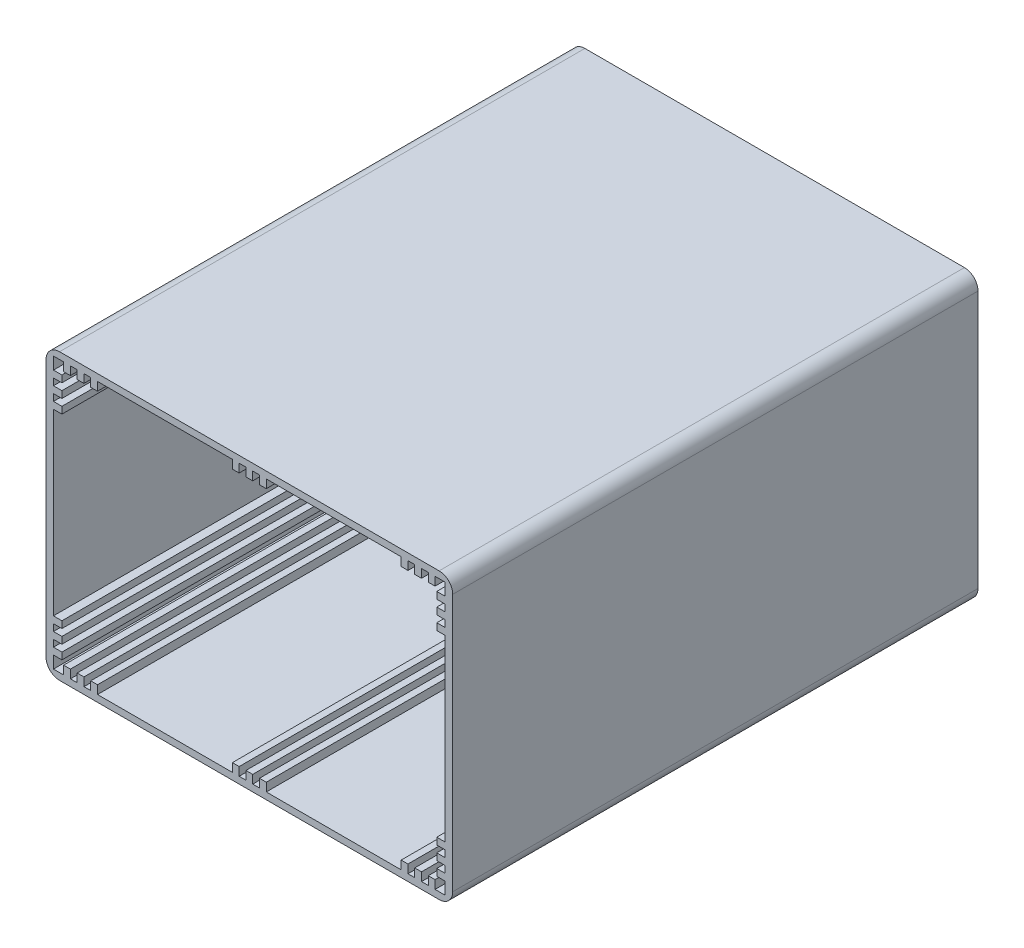
from build123d import *

# Parameters (mm, degrees)
SKETCH1_W           = 120
SKETCH1_H           = 84
SKETCH1_W_2         = 115.6
SKETCH1_H_2         = 80
BOSS_EXTRUDE1_DEPTH = 155
FILLET1_R           = 4
SKETCH3_W           = 2
SKETCH3_H           = 2.5
SKETCH3_W_2         = 2.5
SKETCH3_H_2         = 2
FINALBOX_DEPTH      = 155


with BuildPart() as part:
    # Sketch1 → Boss-Extrude1 (new body)
    with BuildSketch(Plane.XY):
        Rectangle(SKETCH1_W, SKETCH1_H)
        Rectangle(SKETCH1_W_2, SKETCH1_H_2, mode=Mode.SUBTRACT)
    extrude(amount=BOSS_EXTRUDE1_DEPTH)

    # Fillet1
    fillet1_edges = [part.edges().sort_by_distance(p)[0] for p in [
        (60, -42, 77.5),
        (-60, -42, 77.5),
        (-60, 42, 77.5),
        (60, 42, 77.5),
    ]]
    fillet(fillet1_edges, radius=FILLET1_R)

    # Sketch3 → FinalBox (add, through all)
    with BuildSketch(Plane.XY.offset(155)):
        with Locations((-53.8, 38.75)):
            Rectangle(SKETCH3_W, SKETCH3_H)
        with Locations((-49.8, 38.75)):
            Rectangle(SKETCH3_W, SKETCH3_H)
        with Locations((-45.8, 38.75)):
            Rectangle(SKETCH3_W, SKETCH3_H)
        with Locations((-56.55, 35.4)):
            Rectangle(SKETCH3_W_2, SKETCH3_H_2)
        with Locations((-56.55, 31.4)):
            Rectangle(SKETCH3_W_2, SKETCH3_H_2)
        with Locations((-56.55, 27.4)):
            Rectangle(SKETCH3_W_2, SKETCH3_H_2)
        with Locations((56.55, 27.4)):
            Rectangle(SKETCH3_W_2, SKETCH3_H_2)
        with Locations((56.55, 31.4)):
            Rectangle(SKETCH3_W_2, SKETCH3_H_2)
        with Locations((56.55, 35.4)):
            Rectangle(SKETCH3_W_2, SKETCH3_H_2)
        with Locations((53.8, 38.75)):
            Rectangle(SKETCH3_W, SKETCH3_H)
        with Locations((49.8, 38.75)):
            Rectangle(SKETCH3_W, SKETCH3_H)
        with Locations((45.8, 38.75)):
            Rectangle(SKETCH3_W, SKETCH3_H)
        with Locations((45.8, -38.75)):
            Rectangle(SKETCH3_W, SKETCH3_H)
        with Locations((49.8, -38.75)):
            Rectangle(SKETCH3_W, SKETCH3_H)
        with Locations((53.8, -38.75)):
            Rectangle(SKETCH3_W, SKETCH3_H)
        with Locations((56.55, -35.4)):
            Rectangle(SKETCH3_W_2, SKETCH3_H_2)
        with Locations((56.55, -31.4)):
            Rectangle(SKETCH3_W_2, SKETCH3_H_2)
        with Locations((56.55, -27.4)):
            Rectangle(SKETCH3_W_2, SKETCH3_H_2)
        with Locations((-45.8, -38.75)):
            Rectangle(SKETCH3_W, SKETCH3_H)
        with Locations((-49.8, -38.75)):
            Rectangle(SKETCH3_W, SKETCH3_H)
        with Locations((-53.8, -38.75)):
            Rectangle(SKETCH3_W, SKETCH3_H)
        with Locations((-56.55, -35.4)):
            Rectangle(SKETCH3_W_2, SKETCH3_H_2)
        with Locations((-56.55, -31.4)):
            Rectangle(SKETCH3_W_2, SKETCH3_H_2)
        with Locations((-56.55, -27.4)):
            Rectangle(SKETCH3_W_2, SKETCH3_H_2)
        with Locations((-4, -38.75)):
            Rectangle(SKETCH3_W, SKETCH3_H)
        with Locations((-4, 38.75)):
            Rectangle(SKETCH3_W, SKETCH3_H)
        with Locations((0, 38.75)):
            Rectangle(SKETCH3_W, SKETCH3_H)
        with Locations((4, 38.75)):
            Rectangle(SKETCH3_W, SKETCH3_H)
        with Locations((0, -38.75)):
            Rectangle(SKETCH3_W, SKETCH3_H)
        with Locations((4, -38.75)):
            Rectangle(SKETCH3_W, SKETCH3_H)
    extrude(amount=-FINALBOX_DEPTH)


solid = part.part
